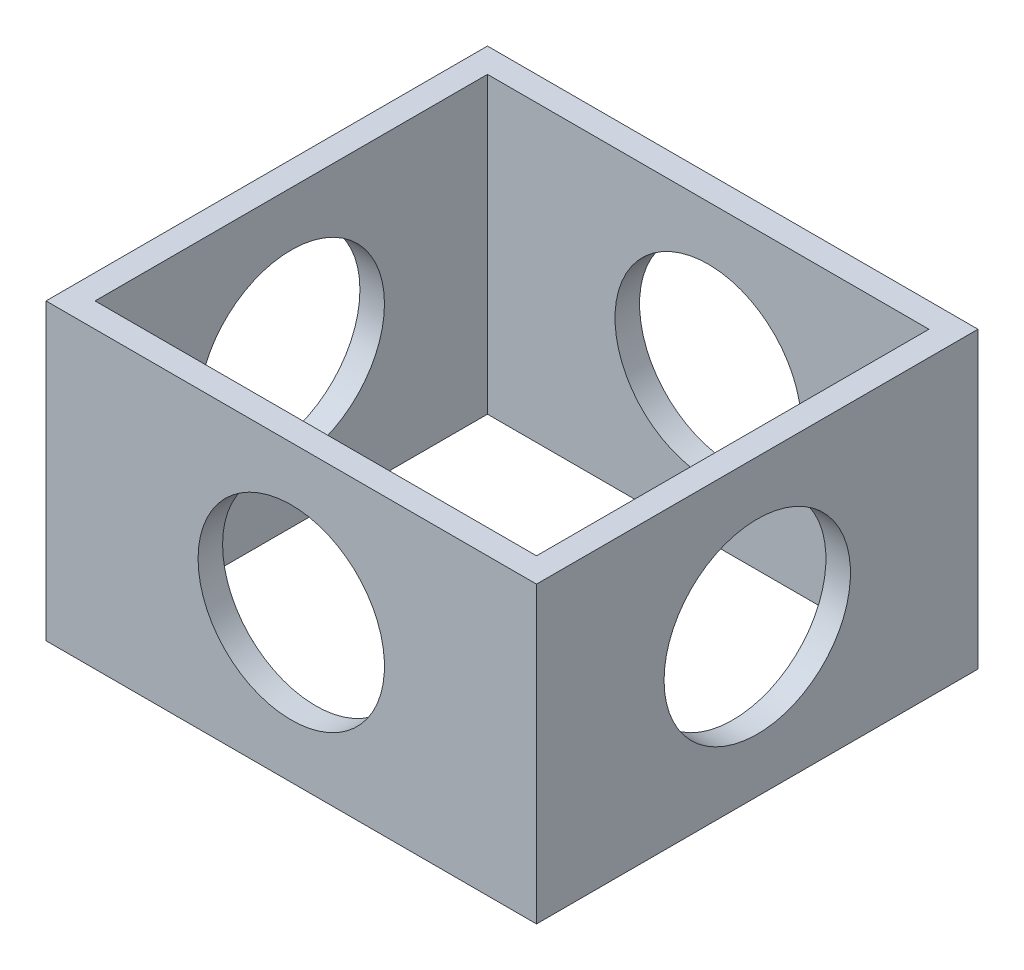
from build123d import *

# Parameters (mm, degrees)
SKETCH2_W               = 50
SKETCH2_H               = 45
SKETCH2_W_2             = 45
SKETCH2_H_2             = 40
BOSS_EXTRUDE1_DEPTH     = 30
SKETCH4_R               = 9.5
CUT_EXTRUDE1_DEPTH      = 1
CUT_EXTRUDE1_DEPTH_BACK = 46
SKETCH5_R               = 9.5
CUT_EXTRUDE2_DEPTH      = 1
CUT_EXTRUDE2_DEPTH_BACK = 51


with BuildPart() as part:
    # Sketch2 → Boss-Extrude1 (new body)
    with BuildSketch(Plane(origin=(0, 0, 0), x_dir=(1, 0, 0), z_dir=(0, 1, 0))):
        Rectangle(SKETCH2_W, SKETCH2_H)
        Rectangle(SKETCH2_W_2, SKETCH2_H_2, mode=Mode.SUBTRACT)
    extrude(amount=BOSS_EXTRUDE1_DEPTH)

    # Sketch4 → Cut-Extrude1 (cut, two sides)
    with BuildSketch(Plane.XY.offset(22.5)) as cut_extrude1_sk:
        with Locations((0, 15)):
            Circle(SKETCH4_R)
    extrude(amount=CUT_EXTRUDE1_DEPTH, mode=Mode.SUBTRACT)
    extrude(cut_extrude1_sk.sketch, amount=-CUT_EXTRUDE1_DEPTH_BACK, mode=Mode.SUBTRACT)

    # Sketch5 → Cut-Extrude2 (cut, two sides)
    with BuildSketch(Plane.ZY.offset(25)) as cut_extrude2_sk:
        with Locations((0, 15)):
            Circle(SKETCH5_R)
    extrude(amount=CUT_EXTRUDE2_DEPTH, mode=Mode.SUBTRACT)
    extrude(cut_extrude2_sk.sketch, amount=-CUT_EXTRUDE2_DEPTH_BACK, mode=Mode.SUBTRACT)


solid = part.part
